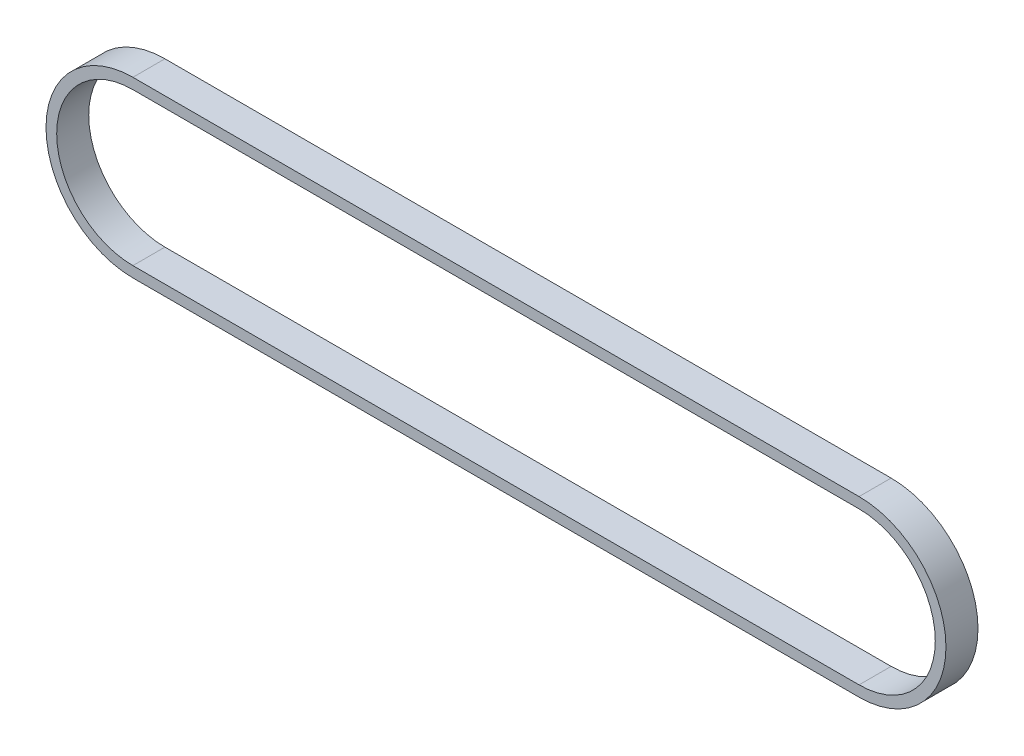
from build123d import *

# Parameters (mm, degrees)
RESSALTO_EXTRUS_O1_DEPTH = 4.5


with BuildPart() as part:
    # Esboço1 → Ressalto-extrusão1 (new body, symmetric)
    with BuildSketch(Plane.XY):
        with BuildLine():
            ThreePointArc((203.94484, -24.4), (228.34484, 0), (203.94484, 24.4))
            Line((203.94484, 24.4), (0, 24.4))
            ThreePointArc((0, 24.4), (-24.4, 0), (0, -24.4))
            Line((0, -24.4), (203.94484, -24.4))
        make_face()
        with BuildLine():
            ThreePointArc((0, -21.4), (-21.4, 0), (0, 21.4))
            Line((0, 21.4), (203.94484, 21.4))
            ThreePointArc((203.94484, 21.4), (225.34484, 0), (203.94484, -21.4))
            Line((203.94484, -21.4), (0, -21.4))
        make_face(mode=Mode.SUBTRACT)
    extrude(amount=RESSALTO_EXTRUS_O1_DEPTH, both=True)


solid = part.part
